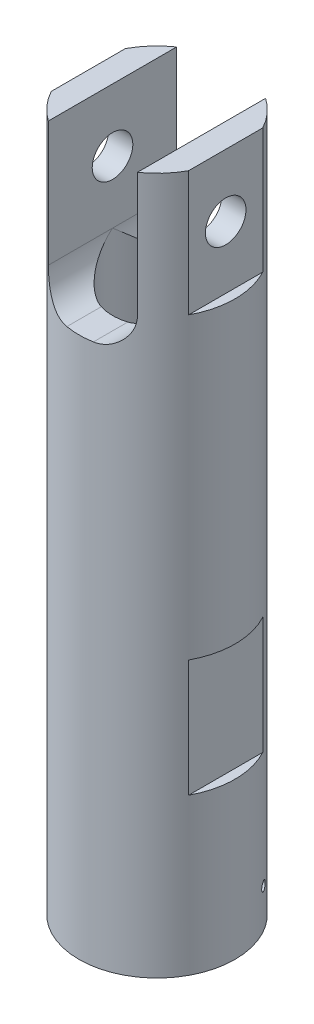
from build123d import *

# Parameters (mm, degrees)
SKETCH1_R                                     = 12.7
SKETCH1_R_2                                   = 4.826
SOCKET_HEAD_STOP_DEPTH                        = 5.08
SKETCH2_R                                     = 12.7
SKETCH2_R_2                                   = 7.239
MAIN_BODY_DEPTH                               = 100.70719
ROD_END_MOUNTING_HOLES_DEPTH                  = 103.29622729
ROD_END_MOUNTING_HOLES_DEPTH_BACK             = 103.29622729
SKETCH6_R                                     = 3.302
ROD_END_BODY_HOLES_AND_WRENCH_CUTS_DEPTH      = 103.296227413
ROD_END_BODY_HOLES_AND_WRENCH_CUTS_DEPTH_BACK = 103.296227413
SKETCH3_W                                     = 1.524
SKETCH3_H                                     = 20.32
SKETCH3_H_2                                   = 19.05
RACK_START                                    = 12.7
SKETCH4_R                                     = 12.7
SKETCH4_R_2                                   = 10.414
RACK_COVER_DEPTH                              = 12.7
SAFETY_WIRE_HOLES_DEPTH                       = 103.296227413
SAFETY_WIRE_HOLES_DEPTH_BACK                  = 103.296227413
SKETCH7_R                                     = 0.762


with BuildPart() as part:
    # Sketch1 → Socket Head Stop (new body)
    with BuildSketch(Plane(origin=(0, 0, 0), x_dir=(1, 0, 0), z_dir=(0, 1, 0))):
        Circle(SKETCH1_R)
        Circle(SKETCH1_R_2, mode=Mode.SUBTRACT)
    extrude(amount=SOCKET_HEAD_STOP_DEPTH)

    # Sketch2 → Main Body (add)
    with BuildSketch(Plane(origin=(0, 0, 0), x_dir=(1, 0, 0), z_dir=(0, 1, 0))):
        Circle(SKETCH2_R)
        Circle(SKETCH2_R_2, mode=Mode.SUBTRACT)
    extrude(amount=MAIN_BODY_DEPTH)

    # Sketch6 → Rod End Mounting Holes (cut, two sides: drawn at the far end of the back side and taken through both)
    with BuildSketch(Plane(origin=(0, 0, 0), x_dir=(0, 0, -1), z_dir=(1, 0, 0)).offset(-ROD_END_MOUNTING_HOLES_DEPTH_BACK)):
        with Locations((0, 90.54719)):
            Circle(SKETCH6_R)
    extrude(amount=ROD_END_MOUNTING_HOLES_DEPTH + ROD_END_MOUNTING_HOLES_DEPTH_BACK, mode=Mode.SUBTRACT)

    # Sketch3 → Rod End Body Holes And Wrench Cuts (cut, two sides: drawn at the far end of the back side and taken through both)
    with BuildSketch(Plane.XY.offset(-ROD_END_BODY_HOLES_AND_WRENCH_CUTS_DEPTH_BACK)):
        with BuildLine():
            Line((7.239, 100.70719), (-7.239, 100.70719))
            Line((-7.239, 100.70719), (-7.239, 80.38719))
            ThreePointArc((-7.239, 80.38719), (-5.751102448, 76.795087552), (-2.159, 75.30719))
            Line((-2.159, 75.30719), (2.159, 75.30719))
            ThreePointArc((2.159, 75.30719), (5.751102448, 76.795087552), (7.239, 80.38719))
            Line((7.239, 80.38719), (7.239, 100.70719))
        make_face()
        with Locations((11.938, 90.54719)):
            Rectangle(SKETCH3_W, SKETCH3_H)
        with Locations((-11.938, 90.54719)):
            Rectangle(SKETCH3_W, SKETCH3_H)
        with Locations((11.938, 22.225)):
            Rectangle(SKETCH3_W, SKETCH3_H_2)
        with Locations((-11.938, 22.225)):
            Rectangle(SKETCH3_W, SKETCH3_H_2)
    extrude(amount=ROD_END_BODY_HOLES_AND_WRENCH_CUTS_DEPTH + ROD_END_BODY_HOLES_AND_WRENCH_CUTS_DEPTH_BACK, mode=Mode.SUBTRACT)

    # Sketch4 → Rack Cover (add)
    with BuildSketch(Plane.XZ.offset(RACK_START)):
        Circle(SKETCH4_R)
        Circle(SKETCH4_R_2, mode=Mode.SUBTRACT)
    extrude(amount=-RACK_COVER_DEPTH)

    # Sketch7 → Safety Wire Holes (cut, two sides: drawn at the far end of the back side and taken through both)
    with BuildSketch(Plane(origin=(0, 0, 0), x_dir=(0, 1, 0), z_dir=(-0.8660254037844328, 0, 0.5000000000000101)).offset(-SAFETY_WIRE_HOLES_DEPTH_BACK)):
        with Locations((-6.35, 0)):
            Circle(SKETCH7_R)
    extrude(amount=SAFETY_WIRE_HOLES_DEPTH + SAFETY_WIRE_HOLES_DEPTH_BACK, mode=Mode.SUBTRACT)


solid = part.part
